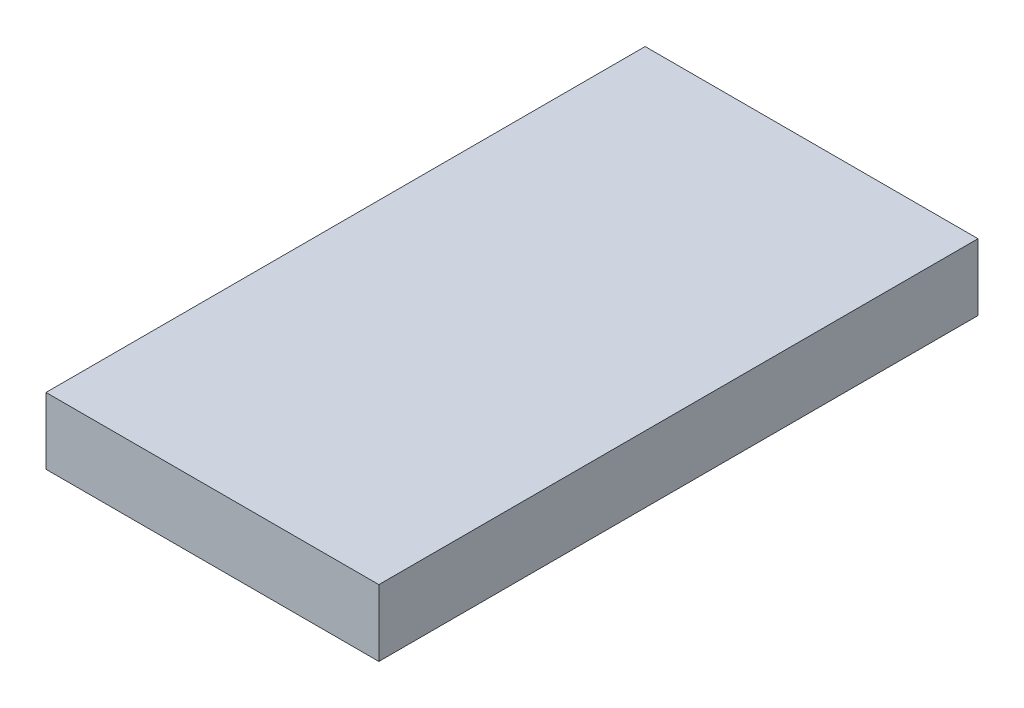
from build123d import *

# Parameters (mm, degrees)
SKETCH1_W      = 63.5
SKETCH1_H      = 114.3
EXTRUDE1_DEPTH = 12.7


with BuildPart() as part:
    # Sketch1 → Extrude1 (new body)
    with BuildSketch(Plane(origin=(0, 0, 0), x_dir=(1, 0, 0), z_dir=(0, 1, 0))):
        with Locations((31.75, 57.15)):
            Rectangle(SKETCH1_W, SKETCH1_H)
    extrude(amount=EXTRUDE1_DEPTH)


solid = part.part
